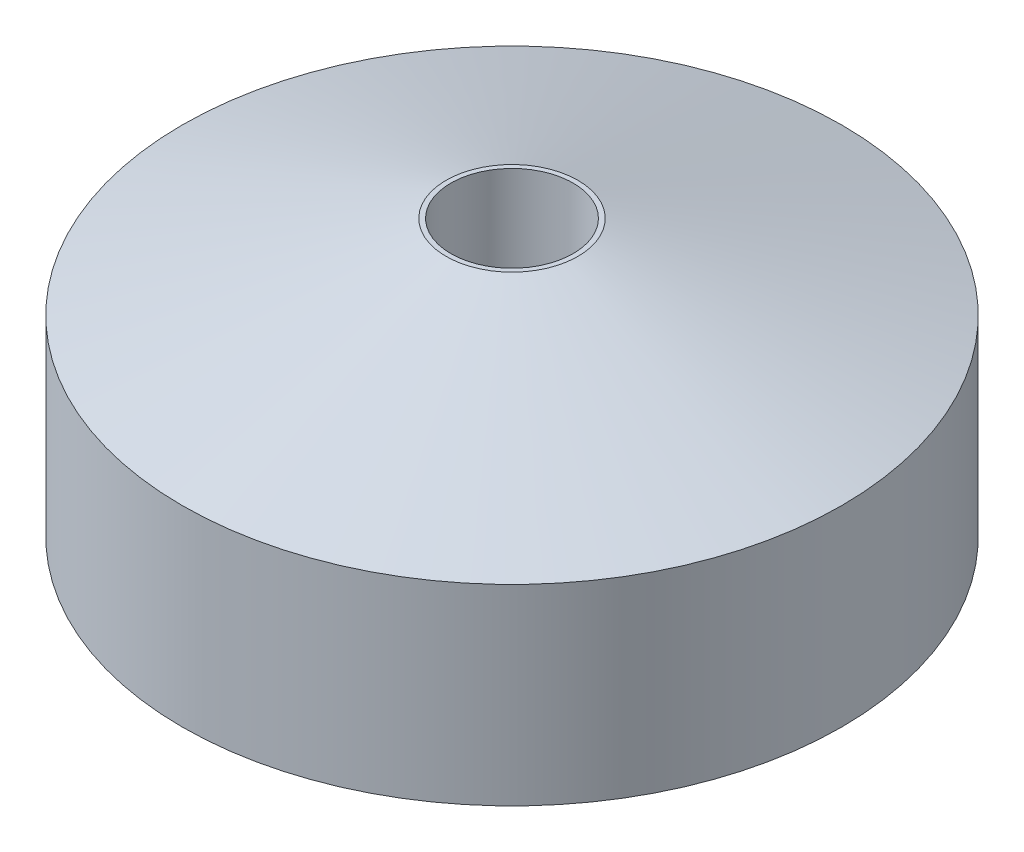
from build123d import *

# Parameters (mm, degrees)
SKETCH1_R                   = 27.5
BOSS_EXTRUDE1_DEPTH         = 23
M12X1_75_TAPPED_HOLE1_D     = 10.2
M12X1_75_TAPPED_HOLE1_DEPTH = 21
M12X1_75_TAPPED_HOLE1_TIP   = 3.064389157
SKETCH9_R                   = 11
CUT_EXTRUDE1_DEPTH          = 10
M8X1_25_TAPPED_HOLE1_D      = 6.8
M8X1_25_TAPPED_HOLE1_DEPTH  = 16
M8X1_25_TAPPED_HOLE1_TIP    = 2.042926105


with BuildPart() as part:
    # Sketch1 → Boss-Extrude1 (new body)
    with BuildSketch(Plane(origin=(0, 0, 0), x_dir=(1, 0, 0), z_dir=(0, 1, 0))):
        Circle(SKETCH1_R)
    extrude(amount=BOSS_EXTRUDE1_DEPTH)

    # Sketch3 → Cut-Revolve1 (revolve, cut)
    with BuildSketch(Plane(origin=(0, 0, 0), x_dir=(0, 0, -1), z_dir=(1, 0, 0))):
        Polygon((-27.5, 16), (-5.5, 23), (-27.5, 23), align=None)
    revolve(axis=Axis((0, 0, 0), (0, 1, 0)), mode=Mode.SUBTRACT)

    # M12x1.75 Tapped Hole1
    with Locations(Plane.ZX.offset(23)):
        with Locations((0, 0)):
            Hole(M12X1_75_TAPPED_HOLE1_D / 2, depth=M12X1_75_TAPPED_HOLE1_DEPTH)
            with Locations((0, 0, -(M12X1_75_TAPPED_HOLE1_DEPTH + M12X1_75_TAPPED_HOLE1_TIP / 2))):  # 118° drill point
                Cone(0, M12X1_75_TAPPED_HOLE1_D / 2, M12X1_75_TAPPED_HOLE1_TIP, mode=Mode.SUBTRACT)

    # Sketch9 → Cut-Extrude1 (cut)
    with BuildSketch(Plane.XZ):
        Circle(SKETCH9_R)
    extrude(amount=-CUT_EXTRUDE1_DEPTH, mode=Mode.SUBTRACT)

    # M8x1.25 Tapped Hole1
    with Locations(Plane(origin=(0, 0, 20), x_dir=(0, 0, -1), z_dir=(0, -1, 0))):
        with Locations((0, 0), (20, 20), (40, 0), (20, -20)):
            Hole(M8X1_25_TAPPED_HOLE1_D / 2, depth=M8X1_25_TAPPED_HOLE1_DEPTH)
            with Locations((0, 0, -(M8X1_25_TAPPED_HOLE1_DEPTH + M8X1_25_TAPPED_HOLE1_TIP / 2))):  # 118° drill point
                Cone(0, M8X1_25_TAPPED_HOLE1_D / 2, M8X1_25_TAPPED_HOLE1_TIP, mode=Mode.SUBTRACT)


solid = part.part
